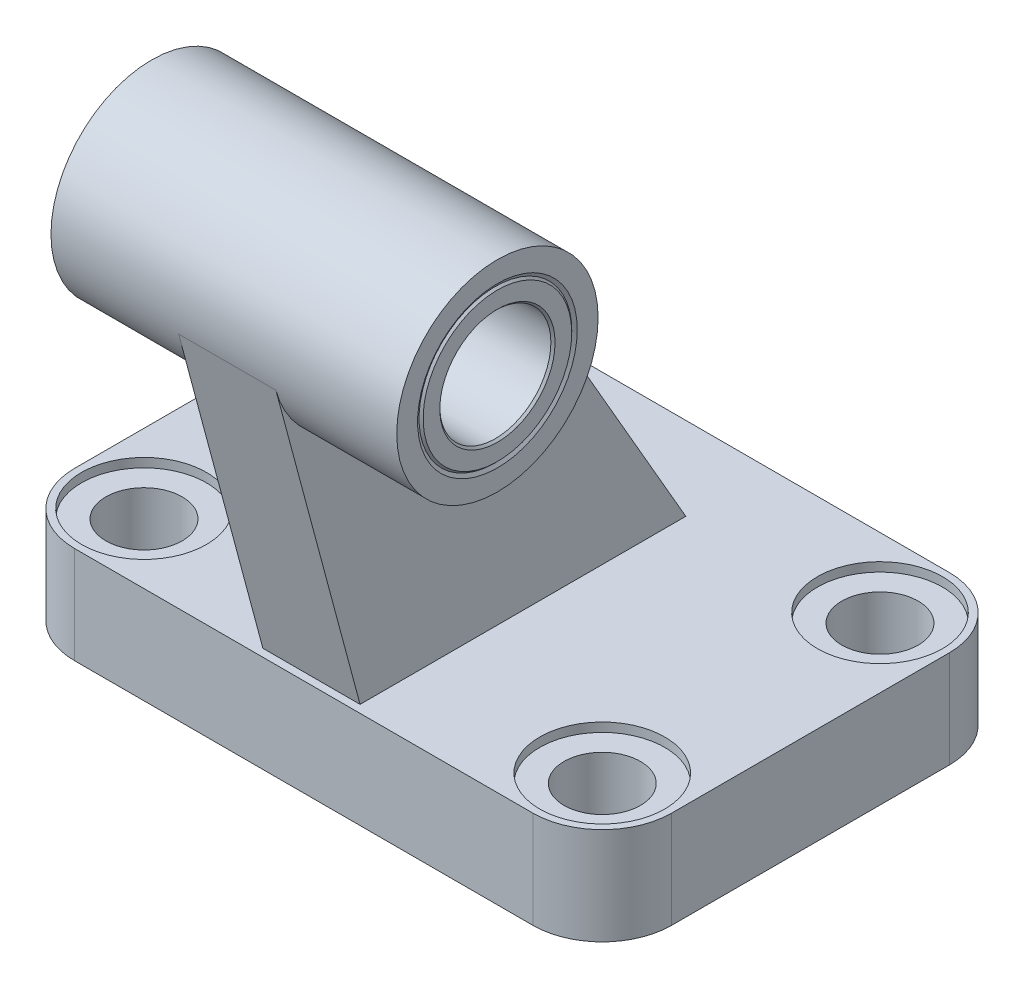
from build123d import *

# Parameters (mm, degrees)
BOSS_EXTRUDE1_DEPTH      = 14
BOSS_EXTRUDE2_DEPTH      = 7
BOSS_EXTRUDE2_DEPTH_BACK = 7
SKETCH3_R                = 14.5
BOSS_EXTRUDE3_DEPTH      = 24.9
BOSS_EXTRUDE3_DEPTH_BACK = 24.9


with BuildPart() as part:
    # Sketch1 → Boss-Extrude1 (new body)
    with BuildSketch(Plane(origin=(0, 0, 0), x_dir=(1, 0, 0), z_dir=(0, 1, 0))):
        with BuildLine():
            Line((-33, -30), (33, -30))
            ThreePointArc((33, -30), (40.071067812, -27.071067812), (43, -20))
            Line((43, -20), (43, 20))
            ThreePointArc((43, 20), (40.071067812, 27.071067812), (33, 30))
            Line((33, 30), (-33, 30))
            ThreePointArc((-33, 30), (-40.071067812, 27.071067812), (-43, 20))
            Line((-43, 20), (-43, -20))
            ThreePointArc((-43, -20), (-40.071067812, -27.071067812), (-33, -30))
        make_face()
    extrude(amount=BOSS_EXTRUDE1_DEPTH)

    # Sketch2 → Boss-Extrude2 (add, two sides)
    with BuildSketch(Plane(origin=(0, 0, 0), x_dir=(0, 0, -1), z_dir=(1, 0, 0))) as boss_extrude2_sk:
        Polygon((-41.005924481, 59.247123846), (-28.881994187, 14), (18.033320997, 14), (-14.442631645, 70.25), align=None)
    extrude(amount=BOSS_EXTRUDE2_DEPTH)
    extrude(boss_extrude2_sk.sketch, amount=-BOSS_EXTRUDE2_DEPTH_BACK)

    # Sketch3 → Boss-Extrude3 (add, two sides)
    with BuildSketch(Plane(origin=(0, 0, 0), x_dir=(0, 0, -1), z_dir=(1, 0, 0))) as boss_extrude3_sk:
        with Locations((-27, 63)):
            Circle(SKETCH3_R)
    extrude(amount=BOSS_EXTRUDE3_DEPTH)
    extrude(boss_extrude3_sk.sketch, amount=-BOSS_EXTRUDE3_DEPTH_BACK)

    # Sketch4 → Cut-Revolve1 (revolve, cut)
    with BuildSketch(Plane.XY.offset(20)):
        Polygon((-33, 0), (-38.5, 0), (-38.5, 12.7), (-42, 12.7), (-42, 14), (-33, 14), align=None)
    revolve(axis=Axis((-33, 14, 20), (0, -1, 0)), mode=Mode.SUBTRACT)

    # Sketch5 → Cut-Revolve2 (revolve, cut)
    with BuildSketch(Plane.XY.offset(-20)):
        Polygon((-33, 0), (-38.5, 0), (-38.5, 12.7), (-42, 12.7), (-42, 14), (-33, 14), align=None)
    revolve(axis=Axis((-33, 14, -20), (0, -1, 0)), mode=Mode.SUBTRACT)

    # Sketch6 → Cut-Revolve3 (revolve, cut)
    with BuildSketch(Plane.XY.offset(20)):
        Polygon((33, 0), (27.5, 0), (27.5, 12.7), (24, 12.7), (24, 14), (33, 14), align=None)
    revolve(axis=Axis((33, 14, 20), (0, -1, 0)), mode=Mode.SUBTRACT)

    # Sketch7 → Cut-Revolve4 (revolve, cut)
    with BuildSketch(Plane.XY.offset(-20)):
        Polygon((33, 0), (27.5, 0), (27.5, 12.7), (24, 12.7), (24, 14), (33, 14), align=None)
    revolve(axis=Axis((33, 14, -20), (0, -1, 0)), mode=Mode.SUBTRACT)

    # Sketch8 → Cut-Revolve5 (revolve, cut)
    with BuildSketch(Plane.XY.offset(27)):
        Polygon((-24.9, 63), (-24.9, 74.5), (-24.611324865, 74), (24.611324865, 74), (24.9, 74.5), (24.9, 63), align=None)
    revolve(axis=Axis((24.9, 63, 27), (-1, 0, 0)), mode=Mode.SUBTRACT)

    # Sketch9 → Revolve1 (revolve)
    with BuildSketch(Plane.XY.offset(27)):
        Polygon((-24.9, 71.3), (-24.6, 71), (24.6, 71), (24.9, 71.3), (24.9, 73.7), (24.6, 74), (-24.6, 74), (-24.9, 73.7), align=None)
    revolve(axis=Axis((24.9, 63, 27), (-1, 0, 0)))


solid = part.part
